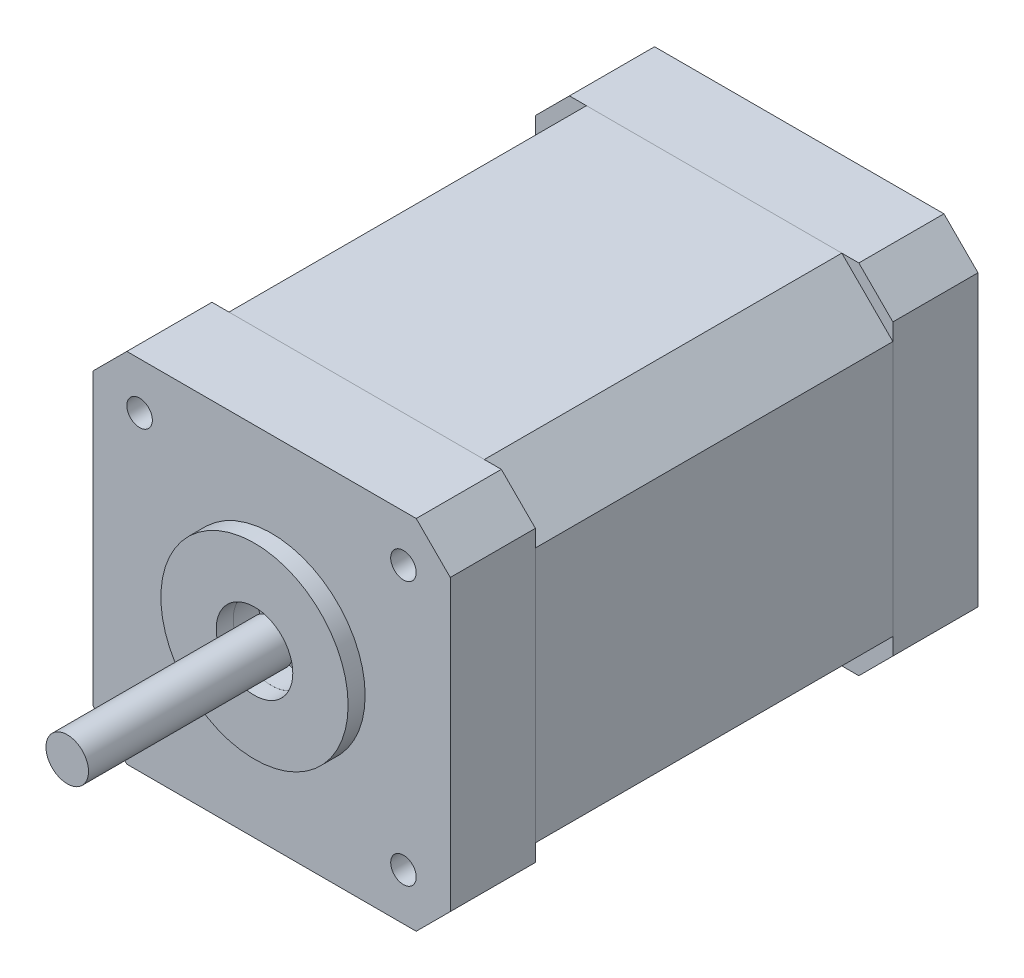
from build123d import *

# Parameters (mm, degrees)
SKETCH_1_W               = 42
SKETCH_1_H               = 42
EXTRUDE_1_DEPTH          = 21
CHAMFER_1_SIZE           = 6
SKETCH_15_W              = 42
SKETCH_15_H              = 42
EXTRUDE_11_DEPTH         = 10
SKETCH_16_W              = 42
SKETCH_16_H              = 42
EXTRUDE_12_DEPTH         = 10
CHAMFER_2_SIZE           = 4
CHAMFER_3_SIZE           = 4
SKETCH_2_R               = 11
EXTRUDE_2_DEPTH          = 2
SKETCH_3_R               = 4.5
CUT_EXTRUDE_1_DEPTH      = 5
SKETCH_6_R               = 2.5
EXTRUDE_9_DEPTH          = 24
SKETCH_8_R               = 1.5
CUT_EXTRUDE_3_DEPTH      = 4.5
PATTERN_CIRCULAR_1_COUNT = 4


with BuildPart() as part:
    # 草圖1 → 填料-伸長1 (new body, symmetric)
    with BuildSketch(Plane.XY):
        Rectangle(SKETCH_1_W, SKETCH_1_H)
    extrude(amount=EXTRUDE_1_DEPTH, both=True)

    # 導角1
    chamfer_1_edges = [part.edges().sort_by_distance(p)[0] for p in [
        (21, -21, 0),
        (-21, -21, 0),
        (-21, 21, 0),
        (21, 21, 0),
    ]]
    chamfer(chamfer_1_edges, length=CHAMFER_1_SIZE)


with BuildPart() as body_2:
    # 草圖15 → 填料-伸長11 (new body)
    with BuildSketch(Plane.XY.offset(21)):
        Rectangle(SKETCH_15_W, SKETCH_15_H)
    extrude(amount=EXTRUDE_11_DEPTH)

    # 導角2
    chamfer_2_edges = [body_2.edges().sort_by_distance(p)[0] for p in [
        (21, -21, 26),
        (-21, -21, 26),
        (-21, 21, 26),
        (21, 21, 26),
    ]]
    chamfer(chamfer_2_edges, length=CHAMFER_2_SIZE)


with BuildPart() as body_3:
    # 草圖16 → 填料-伸長12 (new body)
    with BuildSketch(Plane(origin=(0, 0, -21), x_dir=(-1, 0, 0), z_dir=(0, 0, -1))):
        Rectangle(SKETCH_16_W, SKETCH_16_H)
    extrude(amount=EXTRUDE_12_DEPTH)

    # 導角3
    chamfer_3_edges = [body_3.edges().sort_by_distance(p)[0] for p in [
        (-21, -21, -26),
        (21, -21, -26),
        (21, 21, -26),
        (-21, 21, -26),
    ]]
    chamfer(chamfer_3_edges, length=CHAMFER_3_SIZE)


with BuildPart() as body_4:
    # 草圖2 → 填料-伸長2 (new body)
    with BuildSketch(Plane.XY.offset(31)):
        Circle(SKETCH_2_R)
    extrude(amount=EXTRUDE_2_DEPTH)


with BuildPart() as cut_extrude_1_tool:
    # 草圖3 → 除料-伸長1 (new body)
    with BuildSketch(Plane.XY.offset(33)):
        Circle(SKETCH_3_R)
    extrude(amount=-CUT_EXTRUDE_1_DEPTH)


with BuildPart() as body_2_1:
    add(body_2.part)

    # 除料-伸長1: cut by cut_extrude_1_tool
    add(cut_extrude_1_tool.part, mode=Mode.SUBTRACT)

    # 草圖8 → 除料-伸長3 (cut)
    with BuildSketch(Plane.XY.offset(31)):
        with Locations((-15.5, 15.5)):
            Circle(SKETCH_8_R)
    cut_extrude_3 = extrude(amount=-CUT_EXTRUDE_3_DEPTH, mode=Mode.SUBTRACT)

    # 環狀複製排列1: 除料-伸長3 ×4 about axis
    pattern_circular_1_axis = Axis((0, 0, 0), (0, 0, 1))
    for i in range(1, PATTERN_CIRCULAR_1_COUNT):
        add(cut_extrude_3.rotate(pattern_circular_1_axis, i * 360 / PATTERN_CIRCULAR_1_COUNT), mode=Mode.SUBTRACT)


with BuildPart() as body_4_1:
    add(body_4.part)

    # 除料-伸長1: cut by cut_extrude_1_tool
    add(cut_extrude_1_tool.part, mode=Mode.SUBTRACT)


with BuildPart() as body_5:
    # 草圖6 → 填料-伸長9 (new body)
    with BuildSketch(Plane.XY.offset(31)):
        Circle(SKETCH_6_R)
    extrude(amount=EXTRUDE_9_DEPTH)


solid = Compound([part.part, body_3.part, body_2_1.part, body_4_1.part, body_5.part])
